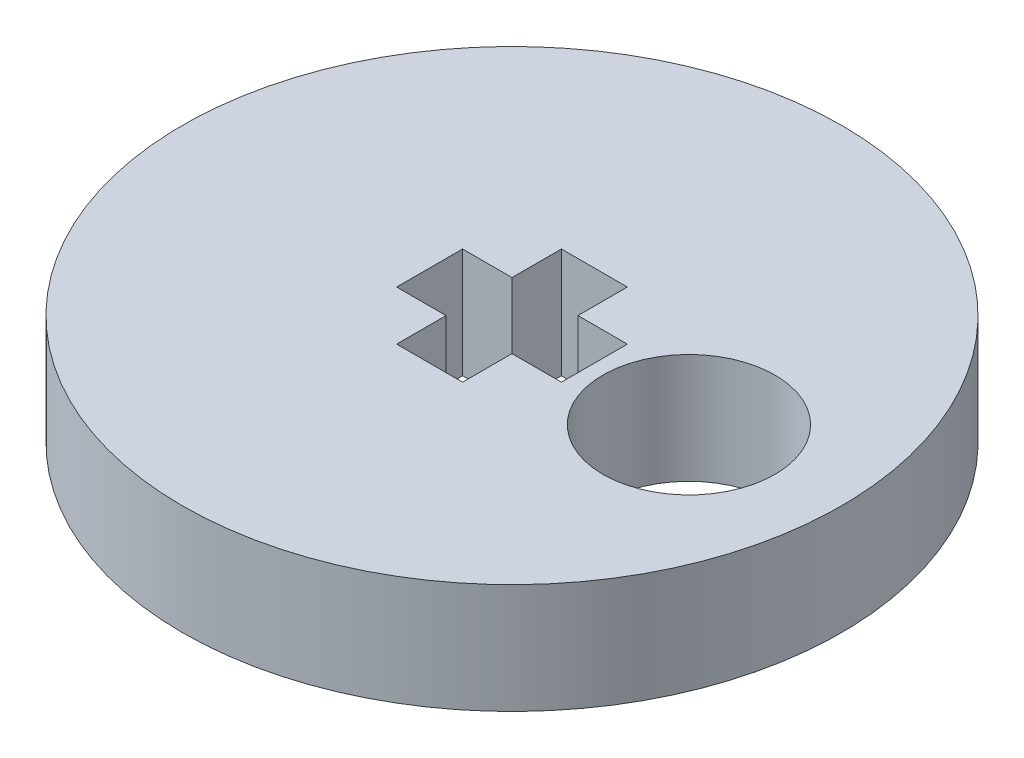
from build123d import *

# Parameters (mm, degrees)
SKETCH1_R           = 9
SKETCH1_R_2         = 2.35
BOSS_EXTRUDE1_DEPTH = 3


with BuildPart() as part:
    # Sketch1 → Boss-Extrude1 (new body)
    with BuildSketch(Plane(origin=(0, 0, 0), x_dir=(1, 0, 0), z_dir=(0, 1, 0))):
        Circle(SKETCH1_R)
        with Locations((4.997281989, -0.164841493)):
            Circle(SKETCH1_R_2, mode=Mode.SUBTRACT)
        Polygon((-2.25, 0.9), (-2.25, -0.9), (-0.9, -0.9), (-0.9, -2.25), (0.9, -2.25), (0.9, -0.9), (2.25, -0.9), (2.25, 0.9), (0.9, 0.9), (0.9, 2.25), (-0.9, 2.25), (-0.9, 0.9), align=None, mode=Mode.SUBTRACT)
    extrude(amount=BOSS_EXTRUDE1_DEPTH)


solid = part.part
